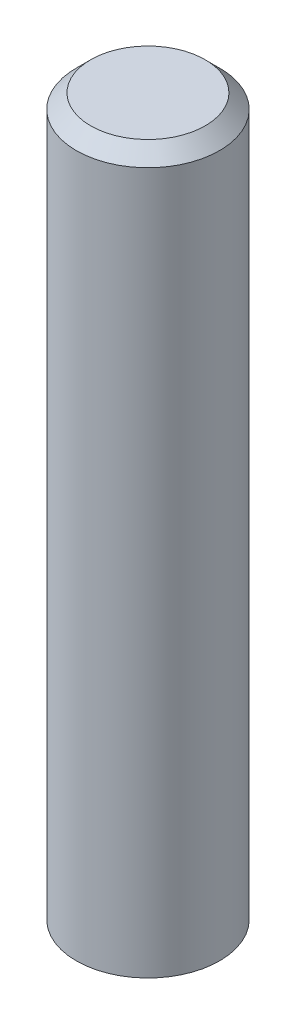
from build123d import *

# Parameters (mm, degrees)
SCHIZZO1_R                   = 0.5
ESTRUSIONE_ESTRUSIONE1_DEPTH = 2.5
SMUSSO1_SIZE                 = 0.1


with BuildPart() as part:
    # Schizzo1 → Estrusione-Estrusione1 (new body, symmetric)
    with BuildSketch(Plane(origin=(0, 0, 0), x_dir=(1, 0, 0), z_dir=(0, 1, 0))):
        Circle(SCHIZZO1_R)
    extrude(amount=ESTRUSIONE_ESTRUSIONE1_DEPTH, both=True)

    # Smusso1
    smusso1_edges = [part.edges().sort_by_distance(p)[0] for p in [
        (-0.5, 2.5, 0),
    ]]
    chamfer(smusso1_edges, length=SMUSSO1_SIZE)


solid = part.part
